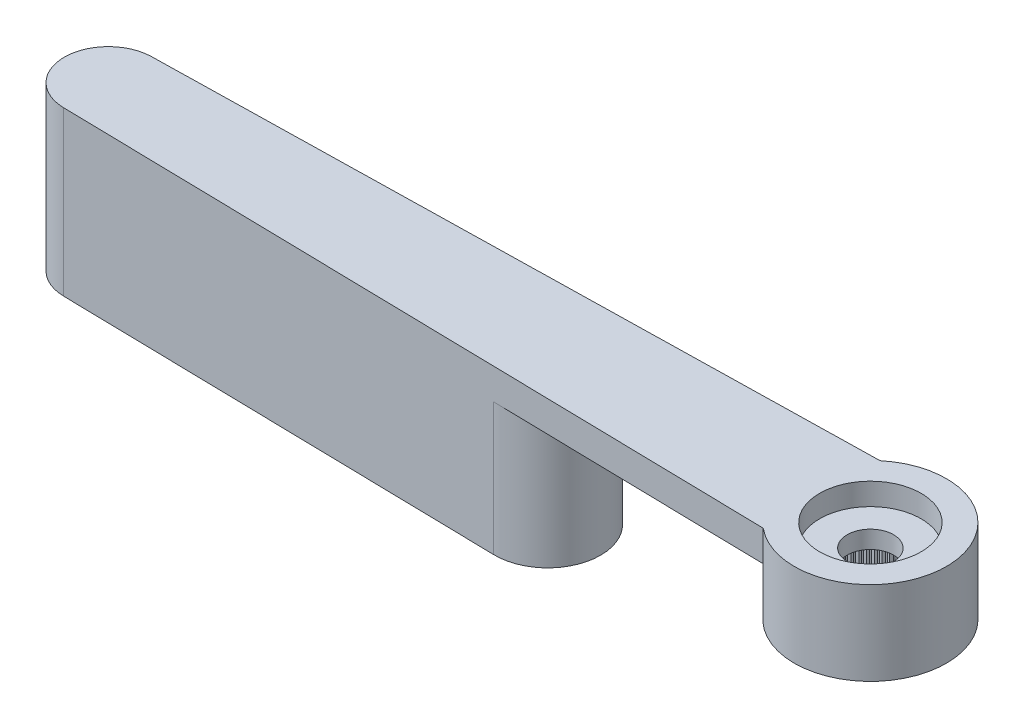
from build123d import *

# Parameters (mm, degrees)
RESSALTO_EXTRUS_O1_DEPTH = 1.4
ESBO_O2_R                = 3.45
RESSALTO_EXTRUS_O2_DEPTH = 2.4
FURO1_D                  = 4.95
FURO1_DEPTH              = 2
FURO2_D                  = 4.6
FURO2_DEPTH              = 1
FURO3_D                  = 2.1
RESSALTO_EXTRUS_O3_DEPTH = 2
PADR_OCIRCULAR1_COUNT    = 60
BOSS_EXTRUDE1_DEPTH      = 6


with BuildPart() as part:
    # Esboço1 → Ressalto-extrusão1 (new body)
    with BuildSketch(Plane(origin=(0, 0, 0), x_dir=(1, 0, 0), z_dir=(0, 1, 0))):
        with BuildLine():
            Line((-34.590163696, 1.999596679), (-2.209072203, 2.65))
            ThreePointArc((-2.209072203, 2.65), (3.45, 0), (-2.209072203, -2.65))
            Line((-2.209072203, -2.65), (-34.590163696, -1.999596679))
            ThreePointArc((-34.590163696, -1.999596679), (-36.55, 0), (-34.590163696, 1.999596679))
        make_face()
    extrude(amount=-RESSALTO_EXTRUS_O1_DEPTH)

    # Esboço2 → Ressalto-extrusão2 (add)
    with BuildSketch(Plane.XZ.offset(1.4)):
        Circle(ESBO_O2_R)
    extrude(amount=RESSALTO_EXTRUS_O2_DEPTH)

    # Furo1
    with Locations(Plane(origin=(0, -3.8, 0), x_dir=(-1, 0, 0), z_dir=(0, -1, 0))):
        with Locations((0, 0)):
            Hole(FURO1_D / 2, depth=FURO1_DEPTH)

    # Furo2
    with Locations(Plane(origin=(0, 0, 0), x_dir=(1, 0, 0), z_dir=(0, 1, 0))):
        with Locations((0, 0)):
            Hole(FURO2_D / 2, depth=FURO2_DEPTH)

    # Furo3 (through all)
    with Locations(Plane(origin=(0, 0, 0), x_dir=(1, 0, 0), z_dir=(0, 1, 0))):
        with Locations((0, 0)):
            Hole(FURO3_D / 2)

    # Esboço11 → Ressalto-extrusão3 (add)
    with BuildSketch(Plane.XZ.offset(3.8)):
        with BuildLine():
            Line((-0.098056786, 2.473056786), (0, 2.375))
            Line((0, 2.375), (0.098056786, 2.473056786))
            ThreePointArc((0.098056786, 2.473056786), (0, 2.475), (-0.098056786, 2.473056786))
        make_face()
    ressalto_extrus_o3 = extrude(amount=-RESSALTO_EXTRUS_O3_DEPTH)

    # PadrãoCircular1: Ressalto-extrusão3 ×60 about axis
    padr_ocircular1_axis = Axis((0, 0, 0), (0, 1, 0))
    for i in range(1, PADR_OCIRCULAR1_COUNT):
        add(ressalto_extrus_o3.rotate(padr_ocircular1_axis, i * 360 / PADR_OCIRCULAR1_COUNT))

    # Sketch1 → Boss-Extrude1 (add)
    with BuildSketch(Plane.XZ.offset(1.4)):
        with BuildLine():
            ThreePointArc((-14.679710941, -2.399516014), (-12.231514506, 0), (-14.679710941, 2.399516014))
            Line((-14.679710941, 2.399516014), (-34.590163696, 1.999596679))
            ThreePointArc((-34.590163696, 1.999596679), (-36.55, 0), (-34.590163696, -1.999596679))
            Line((-34.590163696, -1.999596679), (-14.679710941, -2.399516014))
        make_face()
        with BuildLine():
            Line((-34.560040924, 0.49989917), (-14.649588169, 0.899818505))
            ThreePointArc((-14.649588169, 0.899818505), (-13.731514506, 0), (-14.649588169, -0.899818505))
            Line((-14.649588169, -0.899818505), (-34.560040924, -0.49989917))
            ThreePointArc((-34.560040924, -0.49989917), (-35.05, 0), (-34.560040924, 0.49989917))
        make_face(mode=Mode.SUBTRACT)
    extrude(amount=BOSS_EXTRUDE1_DEPTH)


solid = part.part
